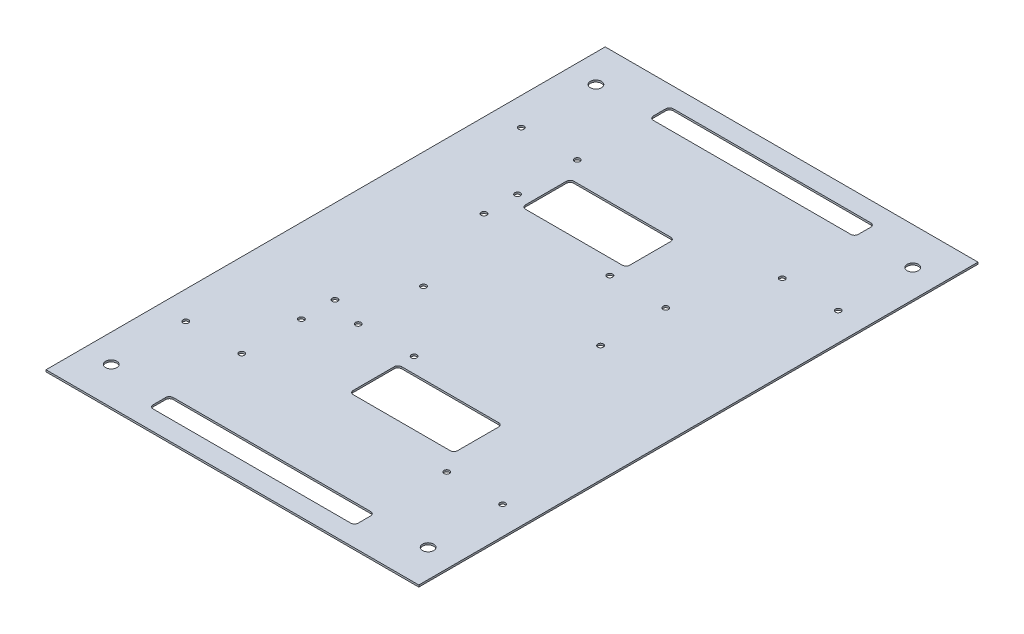
from build123d import *

# Parameters (mm, degrees)
ESQUISSE1_W        = 200
ESQUISSE1_H        = 300
ESQUISSE1_R        = 1.5
ESQUISSE1_R_2      = 3
BOSS_EXTRU_1_DEPTH = 1


with BuildPart() as part:
    # Esquisse1 → Boss.-Extru.1 (new body)
    with BuildSketch(Plane(origin=(0, 0, 0), x_dir=(1, 0, 0), z_dir=(0, 1, 0))):
        Rectangle(ESQUISSE1_W, ESQUISSE1_H)
        with Locations((-37.5, -45)):
            Circle(ESQUISSE1_R, mode=Mode.SUBTRACT)
        with Locations((-7.5, -45)):
            Circle(ESQUISSE1_R, mode=Mode.SUBTRACT)
        with Locations((-37.5, -10)):
            Circle(ESQUISSE1_R, mode=Mode.SUBTRACT)
        with Locations((37.5, 10)):
            Circle(ESQUISSE1_R, mode=Mode.SUBTRACT)
        with Locations((37.5, 45)):
            Circle(ESQUISSE1_R, mode=Mode.SUBTRACT)
        with Locations((7.5, 45)):
            Circle(ESQUISSE1_R, mode=Mode.SUBTRACT)
        with Locations((85, 130)):
            Circle(ESQUISSE1_R_2, mode=Mode.SUBTRACT)
        with Locations((-85, 130)):
            Circle(ESQUISSE1_R_2, mode=Mode.SUBTRACT)
        with Locations((85, -130)):
            Circle(ESQUISSE1_R_2, mode=Mode.SUBTRACT)
        with Locations((-85, -130)):
            Circle(ESQUISSE1_R_2, mode=Mode.SUBTRACT)
        with Locations((-55, 40)):
            Circle(ESQUISSE1_R, mode=Mode.SUBTRACT)
        with Locations((-55, 58)):
            Circle(ESQUISSE1_R, mode=Mode.SUBTRACT)
        with Locations((-55, -58)):
            Circle(ESQUISSE1_R, mode=Mode.SUBTRACT)
        with Locations((-55, -40)):
            Circle(ESQUISSE1_R, mode=Mode.SUBTRACT)
        with Locations((-85, -90)):
            Circle(ESQUISSE1_R, mode=Mode.SUBTRACT)
        with Locations((-55, -90)):
            Circle(ESQUISSE1_R, mode=Mode.SUBTRACT)
        with Locations((85, -90)):
            Circle(ESQUISSE1_R, mode=Mode.SUBTRACT)
        with Locations((55, -90)):
            Circle(ESQUISSE1_R, mode=Mode.SUBTRACT)
        with Locations((55, 90)):
            Circle(ESQUISSE1_R, mode=Mode.SUBTRACT)
        with Locations((85, 90)):
            Circle(ESQUISSE1_R, mode=Mode.SUBTRACT)
        with Locations((-55, 90)):
            Circle(ESQUISSE1_R, mode=Mode.SUBTRACT)
        with Locations((-85, 90)):
            Circle(ESQUISSE1_R, mode=Mode.SUBTRACT)
        with BuildLine():
            Line((-6, -53.175), (46, -53.175))
            ThreePointArc((46, -53.175), (47.414213562, -53.760786438), (48, -55.175))
            Line((48, -55.175), (48, -77.175))
            ThreePointArc((48, -77.175), (47.414213562, -78.589213562), (46, -79.175))
            Line((46, -79.175), (-6, -79.175))
            ThreePointArc((-6, -79.175), (-7.414213562, -78.589213562), (-8, -77.175))
            Line((-8, -77.175), (-8, -55.175))
            ThreePointArc((-8, -55.175), (-7.414213562, -53.760786438), (-6, -53.175))
        make_face(mode=Mode.SUBTRACT)
        with BuildLine():
            Line((-46, 79.175), (6, 79.175))
            ThreePointArc((6, 79.175), (7.414213562, 78.589213562), (8, 77.175))
            Line((8, 77.175), (8, 55.175))
            ThreePointArc((8, 55.175), (7.414213562, 53.760786438), (6, 53.175))
            Line((6, 53.175), (-46, 53.175))
            ThreePointArc((-46, 53.175), (-47.414213562, 53.760786438), (-48, 55.175))
            Line((-48, 55.175), (-48, 77.175))
            ThreePointArc((-48, 77.175), (-47.414213562, 78.589213562), (-46, 79.175))
        make_face(mode=Mode.SUBTRACT)
        with BuildLine():
            Line((-53, -139.5000508), (53, -139.5000508))
            ThreePointArc((53, -139.5000508), (54.414213562, -138.914264362), (55, -137.5000508))
            Line((55, -137.5000508), (55, -130.772848254))
            ThreePointArc((55, -130.772848254), (54.414213562, -129.358634692), (53, -128.772848254))
            Line((53, -128.772848254), (-53, -128.772848254))
            ThreePointArc((-53, -128.772848254), (-54.414213562, -129.358634692), (-55, -130.772848254))
            Line((-55, -130.772848254), (-55, -137.5000508))
            ThreePointArc((-55, -137.5000508), (-54.414213562, -138.914264362), (-53, -139.5000508))
        make_face(mode=Mode.SUBTRACT)
        with BuildLine():
            Line((-55, 137.5000508), (-55, 130.772848254))
            ThreePointArc((-55, 130.772848254), (-54.414213562, 129.358634692), (-53, 128.772848254))
            Line((-53, 128.772848254), (53, 128.772848254))
            ThreePointArc((53, 128.772848254), (54.414213562, 129.358634692), (55, 130.772848254))
            Line((55, 130.772848254), (55, 137.5000508))
            ThreePointArc((55, 137.5000508), (54.414213562, 138.914264362), (53, 139.5000508))
            Line((53, 139.5000508), (-53, 139.5000508))
            ThreePointArc((-53, 139.5000508), (-54.414213562, 138.914264362), (-55, 137.5000508))
        make_face(mode=Mode.SUBTRACT)
    extrude(amount=BOSS_EXTRU_1_DEPTH)


solid = part.part
